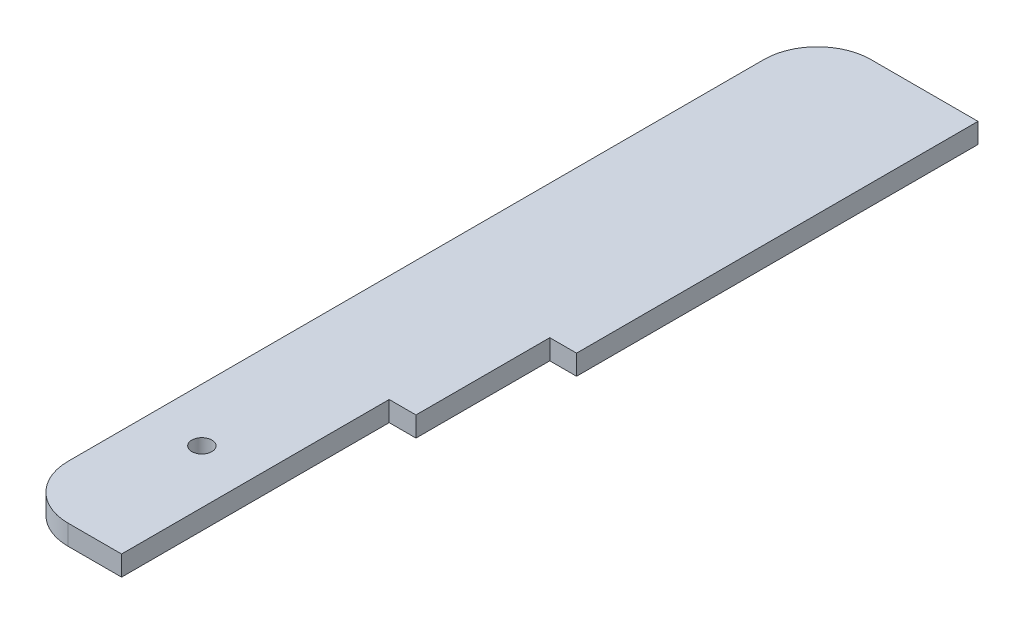
from build123d import *

# Parameters (mm, degrees)
BOSS_EXTRUDE1_DEPTH              = 4.7625
FILLET1_R                        = 25.4
F_3_8_0_375_DIAMETER_HOLE1_D     = 9.525
F_3_8_0_375_DIAMETER_HOLE1_DEPTH = 11.684
F_3_8_0_375_DIAMETER_HOLE1_TIP   = 2.861598698


with BuildPart() as part:
    # Sketch1 → Boss-Extrude1 (new body, symmetric)
    with BuildSketch(Plane(origin=(0, 0, 0), x_dir=(1, 0, 0), z_dir=(0, 1, 0))):
        Polygon((0, 0), (-50.8, 0), (-50.8, 381), (25.4, 381), (25.4, 190.5), (12.7, 190.5), (12.7, 127), (0, 127), align=None)
    extrude(amount=BOSS_EXTRUDE1_DEPTH, both=True)

    # Fillet1
    fillet1_edges = [part.edges().sort_by_distance(p)[0] for p in [
        (-50.8, 0, 0),
        (-50.8, 0, -381),
    ]]
    fillet(fillet1_edges, radius=FILLET1_R)

    # 3/8 (0.375) Diameter Hole1
    with Locations(Plane(origin=(0, 4.7625, 0), x_dir=(1, 0, 0), z_dir=(0, 1, 0))):
        with Locations((-25.4, 63.5)):
            Hole(F_3_8_0_375_DIAMETER_HOLE1_D / 2, depth=F_3_8_0_375_DIAMETER_HOLE1_DEPTH)
            with Locations((0, 0, -(F_3_8_0_375_DIAMETER_HOLE1_DEPTH + F_3_8_0_375_DIAMETER_HOLE1_TIP / 2))):  # 118° drill point
                Cone(0, F_3_8_0_375_DIAMETER_HOLE1_D / 2, F_3_8_0_375_DIAMETER_HOLE1_TIP, mode=Mode.SUBTRACT)


solid = part.part
